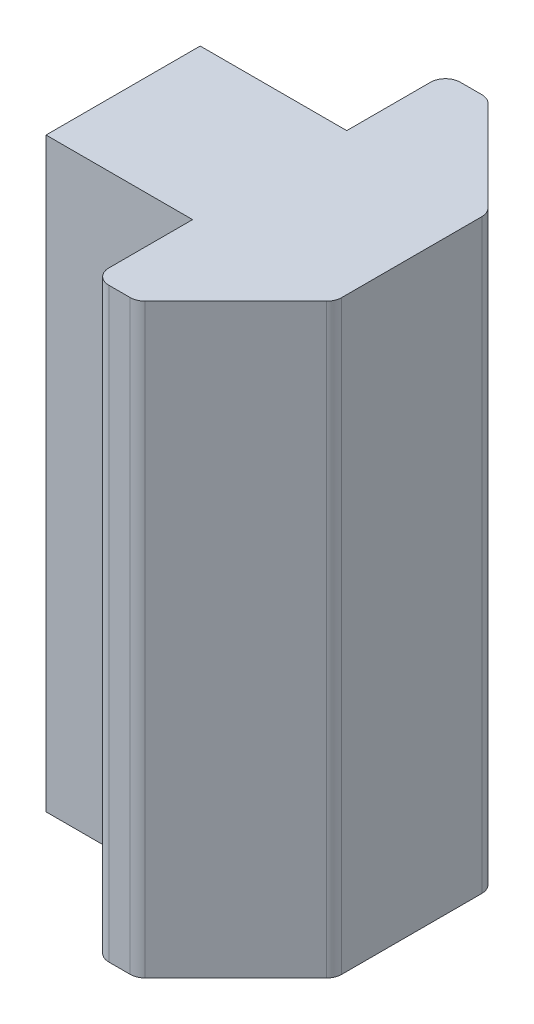
from build123d import *

# Parameters (mm, degrees)
BOSS_EXTRUDE1_DEPTH = 20
SKETCH2_R           = 2.1
CUT_EXTRUDE1_DEPTH  = 6


with BuildPart() as part:
    # Sketch1 → Boss-Extrude1 (new body)
    with BuildSketch(Plane(origin=(0, 0, 0), x_dir=(1, 0, 0), z_dir=(0, 1, 0))):
        with BuildLine():
            Line((-4.847127702, 5.487127702), (-4.847127702, 2.63))
            Line((-4.847127702, 2.63), (-9.847127702, 2.63))
            Line((-9.847127702, 2.63), (-9.847127702, -2.63))
            Line((-9.847127702, -2.63), (-4.847127702, -2.63))
            Line((-4.847127702, -2.63), (-4.847127702, -5.487127702))
            ThreePointArc((-4.847127702, -5.487127702), (-4.69775216, -5.84775216), (-4.337127702, -5.997127702))
            Line((-4.337127702, -5.997127702), (-3.607127702, -5.997127702))
            ThreePointArc((-3.607127702, -5.997127702), (-3.411959151, -5.958306263), (-3.246503243, -5.84775216))
            Line((-3.246503243, -5.84775216), (-0.149375542, -2.750624458))
            ThreePointArc((-0.149375542, -2.750624458), (-0.038821438, -2.585168551), (0, -2.39))
            Line((0, -2.39), (0, 2.39))
            ThreePointArc((0, 2.39), (-0.038821438, 2.585168551), (-0.149375542, 2.750624458))
            Line((-0.149375542, 2.750624458), (-3.246503243, 5.84775216))
            ThreePointArc((-3.246503243, 5.84775216), (-3.411959151, 5.958306263), (-3.607127702, 5.997127702))
            Line((-3.607127702, 5.997127702), (-4.337127702, 5.997127702))
            ThreePointArc((-4.337127702, 5.997127702), (-4.69775216, 5.84775216), (-4.847127702, 5.487127702))
        make_face()
    extrude(amount=BOSS_EXTRUDE1_DEPTH)

    # Sketch2 → Cut-Extrude1 (cut)
    with BuildSketch(Plane.ZY.offset(9.847127702)):
        with Locations((0, 10)):
            Circle(SKETCH2_R)
    extrude(amount=-CUT_EXTRUDE1_DEPTH, mode=Mode.SUBTRACT)


solid = part.part
